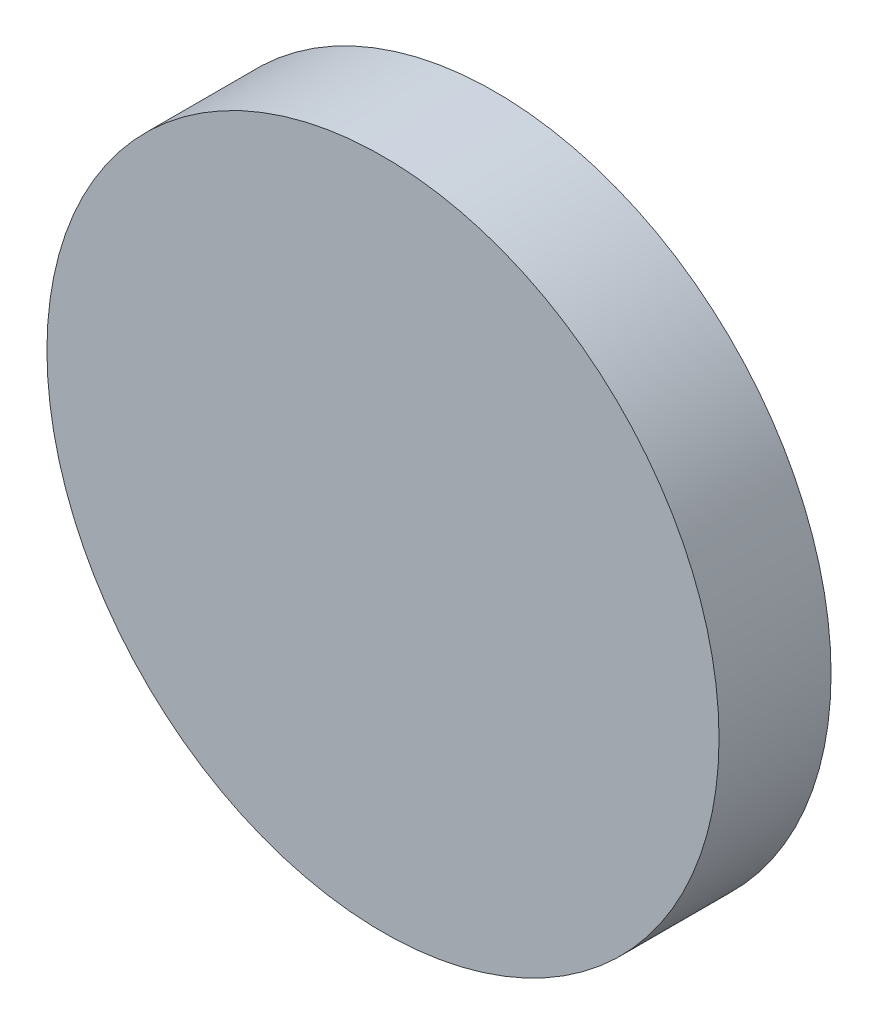
from build123d import *

# Parameters (mm, degrees)
SKETCH_1_R      = 1.5
EXTRUDE_1_DEPTH = 0.5


with BuildPart() as part:
    # 草图1 → 凸台-拉伸1 (new body)
    with BuildSketch(Plane.XY):
        Circle(SKETCH_1_R)
    extrude(amount=EXTRUDE_1_DEPTH)


solid = part.part
